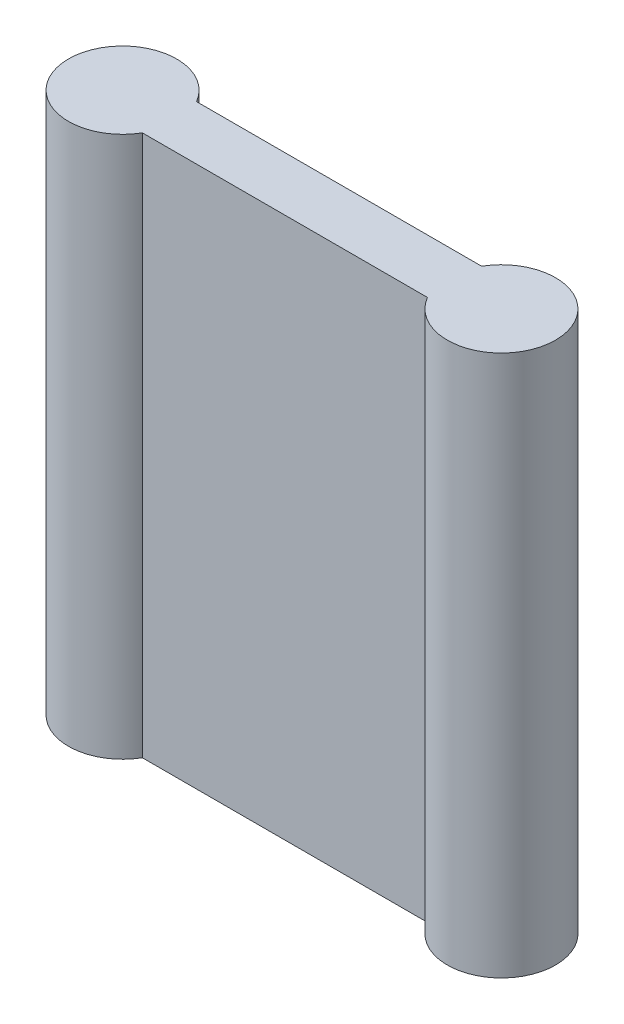
from build123d import *

# Parameters (mm, degrees)
SKETCH1_W           = 14
SKETCH1_H           = 20
BOSS_EXTRUDE1_DEPTH = 2
SKETCH4_R           = 2
BOSS_EXTRUDE4_DEPTH = 20


with BuildPart() as part:
    # Sketch1 → Boss-Extrude1 (new body)
    with BuildSketch(Plane.XY):
        Rectangle(SKETCH1_W, SKETCH1_H)
    extrude(amount=BOSS_EXTRUDE1_DEPTH)

    # Sketch4 → Boss-Extrude4 (add)
    with BuildSketch(Plane.XZ.offset(10)):
        with Locations((-7, 1)):
            Circle(SKETCH4_R)
        with Locations((7, 1)):
            Circle(SKETCH4_R)
    extrude(amount=-BOSS_EXTRUDE4_DEPTH)


solid = part.part
